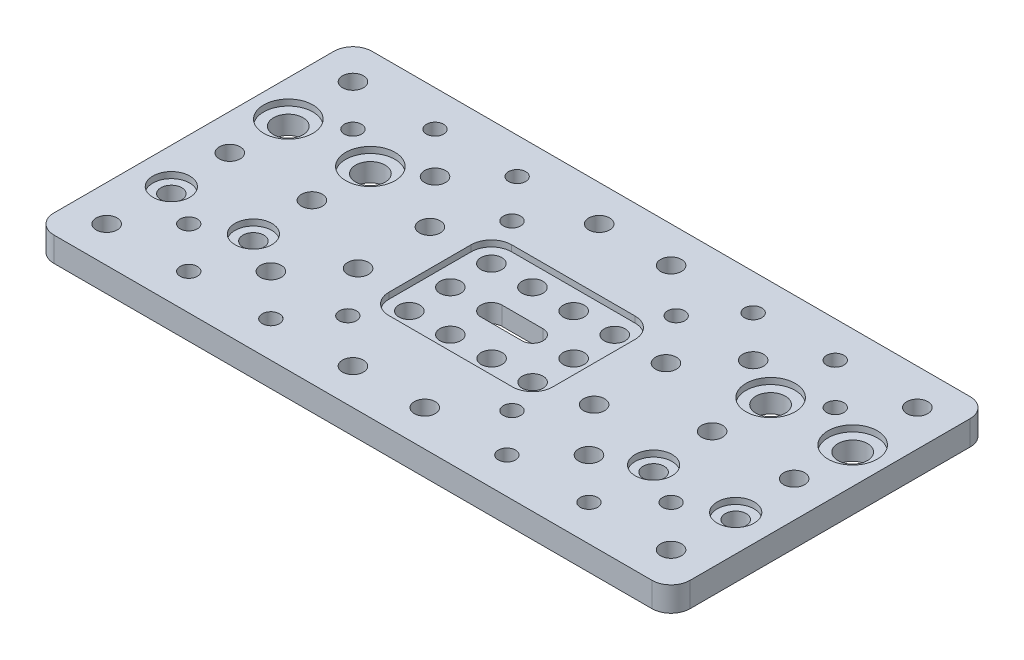
from build123d import *

# Parameters (mm, degrees)
BOSS_EXTRUDE1_DEPTH        = 6
F_5_1_5_1_DIAMETER_HOLE1_D = 5.1
M5X0_8_TAPPED_HOLE1_D      = 4.2
SKETCH6_R                  = 3.6
SKETCH6_R_2                = 2.55
CUT_EXTRUDE1_DEPTH         = 7
SKETCH7_R                  = 6
SKETCH7_R_2                = 4.5
CUT_EXTRUDE2_DEPTH         = 1.5
CUT_EXTRUDE3_DEPTH         = 5.5


with BuildPart() as part:
    # Sketch1 → Boss-Extrude1 (new body)
    with BuildSketch(Plane(origin=(0, 0, 0), x_dir=(1, 0, 0), z_dir=(0, 1, 0))):
        with BuildLine():
            Line((4.64, 0), (150.38, 0))
            ThreePointArc((150.38, 0), (153.660975465, 1.359024535), (155.02, 4.64))
            Line((155.02, 4.64), (155.02, 72.88))
            ThreePointArc((155.02, 72.88), (153.660975465, 76.160975465), (150.38, 77.52))
            Line((150.38, 77.52), (4.64, 77.52))
            ThreePointArc((4.64, 77.52), (1.359024535, 76.160975465), (0, 72.88))
            Line((0, 72.88), (0, 4.64))
            ThreePointArc((0, 4.64), (1.359024535, 1.359024535), (4.64, 0))
        make_face()
    extrude(amount=BOSS_EXTRUDE1_DEPTH)

    # Ø5.1 (5.1) Diameter Hole1 (through all)
    with Locations(Plane(origin=(0, 6, 0), x_dir=(1, 0, 0), z_dir=(0, 1, 0))):
        with Locations((8.755, 68.76), (8.755, 38.76), (28.755, 38.76), (38.755, 58.76), (48.755, 47.515), (68.755, 68.76), (62.485, 48.76), (72.485, 48.76), (62.485, 38.76), (92.535, 38.76), (82.535, 48.76), (92.535, 48.76), (86.265, 68.76), (106.265, 47.515), (116.265, 58.76), (126.265, 38.76), (146.265, 38.76), (146.265, 68.76), (146.265, 8.76), (116.265, 18.76), (106.265, 30.005), (92.535, 28.76), (82.535, 28.76), (86.265, 8.76), (68.755, 8.76), (72.485, 28.76), (62.485, 28.76), (48.755, 30.005), (38.755, 18.76), (8.755, 8.76)):
            Hole(F_5_1_5_1_DIAMETER_HOLE1_D / 2)

    # M5x0.8 Tapped Hole1 (through all)
    with Locations(Plane(origin=(0, 6, 0), x_dir=(1, 0, 0), z_dir=(0, 1, 0))):
        with Locations((18.75, 58.76), (28.755, 68.76), (48.755, 68.76), (57.51, 58.76), (48.755, 8.76), (57.51, 18.76), (18.75, 18.76), (28.755, 8.76), (106.265, 68.76), (97.51, 58.76), (97.51, 18.76), (106.265, 8.76), (126.265, 8.76), (136.27, 18.76), (126.265, 68.76), (136.27, 58.76)):
            Hole(M5X0_8_TAPPED_HOLE1_D / 2)

    # Sketch6 → Cut-Extrude1 (cut, through all)
    with BuildSketch(Plane(origin=(0, 6, 0), x_dir=(1, 0, 0), z_dir=(0, 1, 0))):
        with Locations((8.755, 53.01)):
            Circle(SKETCH6_R)
        with Locations((28.755, 53.01)):
            Circle(SKETCH6_R)
        with Locations((8.755, 24.51)):
            Circle(SKETCH6_R_2)
        with Locations((28.755, 24.51)):
            Circle(SKETCH6_R_2)
        with Locations((126.265, 24.51)):
            Circle(SKETCH6_R_2)
        with Locations((146.265, 24.51)):
            Circle(SKETCH6_R_2)
        with Locations((126.265, 53.01)):
            Circle(SKETCH6_R)
        with Locations((146.265, 53.01)):
            Circle(SKETCH6_R)
    extrude(amount=-CUT_EXTRUDE1_DEPTH, mode=Mode.SUBTRACT)

    # Sketch7 → Cut-Extrude2 (cut)
    with BuildSketch(Plane(origin=(0, 6, 0), x_dir=(1, 0, 0), z_dir=(0, 1, 0))):
        with Locations((8.755, 53.01)):
            Circle(SKETCH7_R)
        with Locations((28.755, 53.01)):
            Circle(SKETCH7_R)
        with Locations((8.755, 24.51)):
            Circle(SKETCH7_R_2)
        with Locations((28.755, 24.51)):
            Circle(SKETCH7_R_2)
        with Locations((126.265, 24.51)):
            Circle(SKETCH7_R_2)
        with Locations((146.265, 24.51)):
            Circle(SKETCH7_R_2)
        with Locations((126.265, 53.01)):
            Circle(SKETCH7_R)
        with Locations((146.265, 53.01)):
            Circle(SKETCH7_R)
        with BuildLine():
            Line((62.475, 53.71), (92.545, 53.71))
            ThreePointArc((92.545, 53.71), (96.038107499, 52.263107499), (97.485, 48.77))
            Line((97.485, 48.77), (97.485, 28.75))
            ThreePointArc((97.485, 28.75), (96.038107499, 25.256892501), (92.545, 23.81))
            Line((92.545, 23.81), (62.475, 23.81))
            ThreePointArc((62.475, 23.81), (58.981892501, 25.256892501), (57.535, 28.75))
            Line((57.535, 28.75), (57.535, 48.77))
            ThreePointArc((57.535, 48.77), (58.981892501, 52.263107499), (62.475, 53.71))
        make_face()
    extrude(amount=-CUT_EXTRUDE2_DEPTH, mode=Mode.SUBTRACT)

    # Sketch8 → Cut-Extrude3 (cut, through all)
    with BuildSketch(Plane(origin=(0, 4.5, 0), x_dir=(1, 0, 0), z_dir=(0, 1, 0))):
        with BuildLine():
            Line((72.485, 41.31), (82.535, 41.31))
            ThreePointArc((82.535, 41.31), (85.085, 38.76), (82.535, 36.21))
            Line((82.535, 36.21), (72.485, 36.21))
            ThreePointArc((72.485, 36.21), (69.935, 38.76), (72.485, 41.31))
        make_face()
    extrude(amount=-CUT_EXTRUDE3_DEPTH, mode=Mode.SUBTRACT)


solid = part.part
